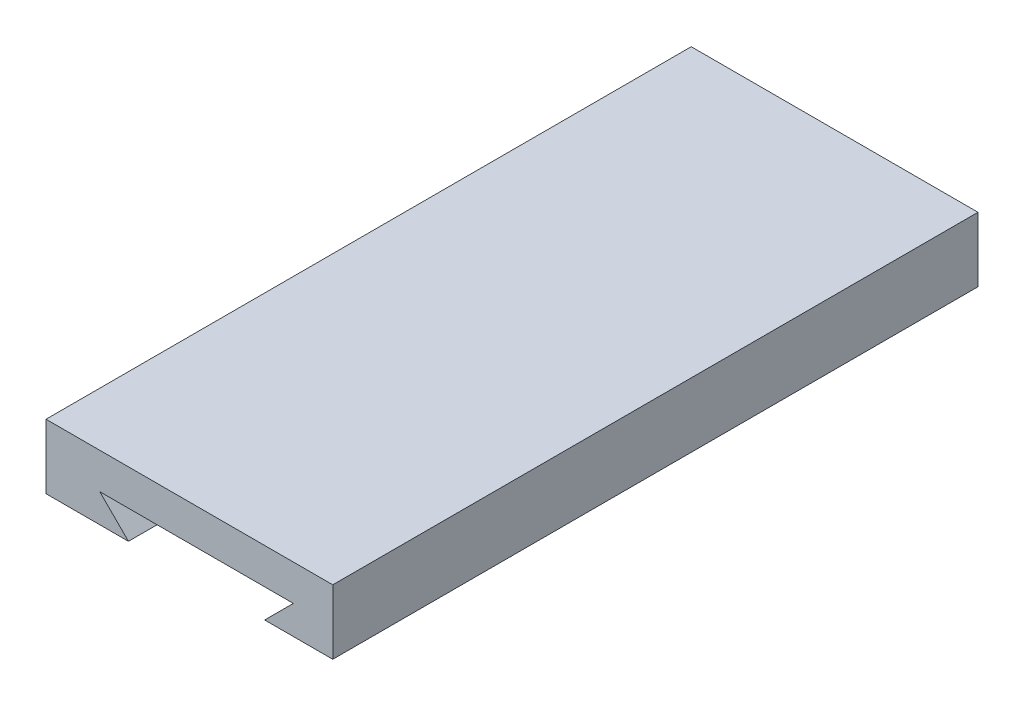
from build123d import *

# Parameters (mm, degrees)
SKETCH1_W               = 80
SKETCH1_H               = 18
BOSS_EXTRUDE1_DEPTH     = 180
CUT_EXTRUDE1_DEPTH      = 1
CUT_EXTRUDE1_DEPTH_BACK = 180


with BuildPart() as part:
    # Sketch1 → Boss-Extrude1 (new body)
    with BuildSketch(Plane.XY):
        with Locations((-11.021069692, 14.824959481)):
            Rectangle(SKETCH1_W, SKETCH1_H)
    extrude(amount=BOSS_EXTRUDE1_DEPTH)

    # Sketch2 → Cut-Extrude1 (cut, two sides)
    with BuildSketch(Plane.XY.offset(180)) as cut_extrude1_sk:
        Polygon((-28.021069692, 5.824959481), (-36.021069692, 13.824959481), (17.978930308, 13.824959481), (9.978930308, 5.824959481), align=None)
    extrude(amount=CUT_EXTRUDE1_DEPTH, mode=Mode.SUBTRACT)
    extrude(cut_extrude1_sk.sketch, amount=-CUT_EXTRUDE1_DEPTH_BACK, mode=Mode.SUBTRACT)


solid = part.part
